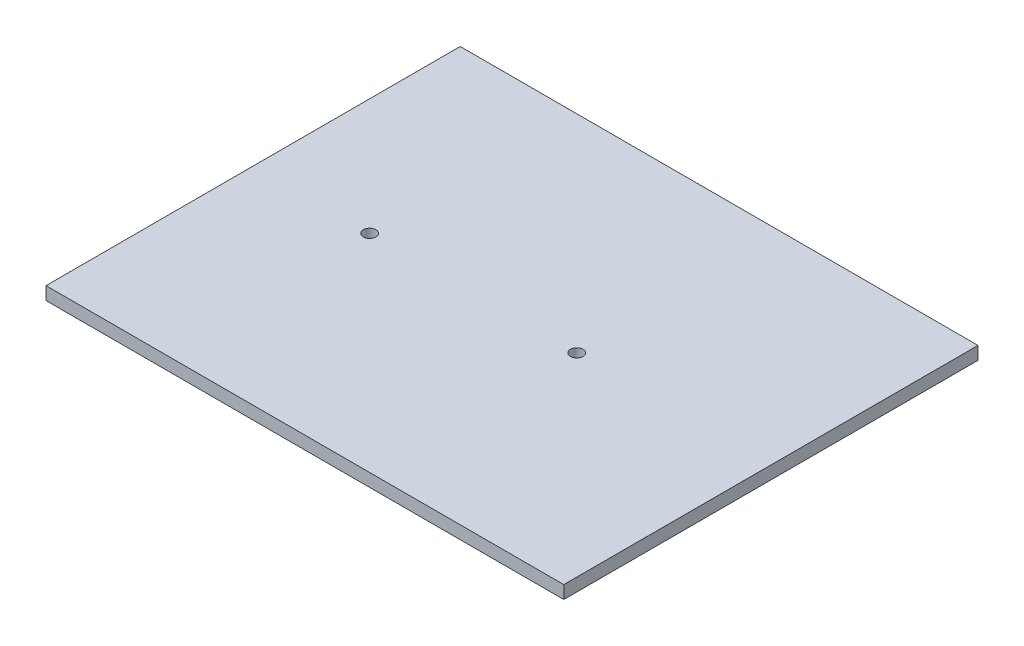
from build123d import *

# Parameters (mm, degrees)
SKETCH1_W           = 254
SKETCH1_H           = 203.2
SKETCH1_R           = 3.0861
BOSS_EXTRUDE1_DEPTH = 6.35


with BuildPart() as part:
    # Sketch1 → Boss-Extrude1 (new body)
    with BuildSketch(Plane(origin=(0, 0, 0), x_dir=(1, 0, 0), z_dir=(0, 1, 0))):
        Rectangle(SKETCH1_W, SKETCH1_H)
        with Locations((-69.85, 0)):
            Circle(SKETCH1_R, mode=Mode.SUBTRACT)
        with Locations((31.75, 0)):
            Circle(SKETCH1_R, mode=Mode.SUBTRACT)
    extrude(amount=BOSS_EXTRUDE1_DEPTH)


solid = part.part
